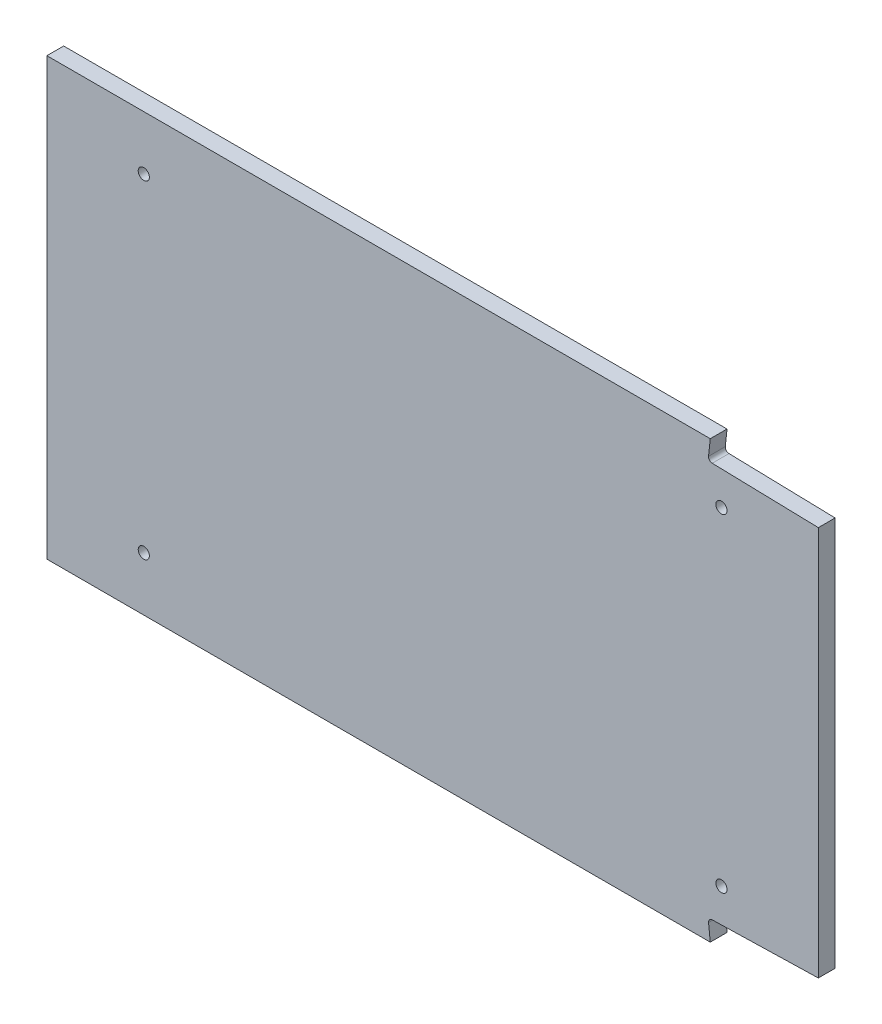
from build123d import *

# Parameters (mm, degrees)
SKETCH1_W               = 207
SKETCH1_H               = 117
BOSS_EXTRUDE1_DEPTH     = 4.5
SKETCH2_R               = 1.5
CUT_EXTRUDE1_DEPTH      = 5.5
MIRROR3_COPY_1_SKETCH_R = 1.5
MIRROR3_COPY_1_DEPTH    = 5.5
CUT_EXTRUDE2_DEPTH      = 4.5


with BuildPart() as part:
    # Sketch1 → Boss-Extrude1 (new body)
    with BuildSketch(Plane.XY):
        Rectangle(SKETCH1_W, SKETCH1_H)
    extrude(amount=BOSS_EXTRUDE1_DEPTH)

    # Sketch2 → Cut-Extrude1 (cut, through all)
    with BuildSketch(Plane.XY.offset(4.5)):
        with Locations((-77.5, 44)):
            Circle(SKETCH2_R)
    cut_extrude1 = extrude(amount=-CUT_EXTRUDE1_DEPTH, mode=Mode.SUBTRACT)

    # Mirror1: Cut-Extrude1 across plane
    add(cut_extrude1.mirror(Plane(origin=(0, 0, 0), x_dir=(0, 0, 1), z_dir=(1, 0, 0))), mode=Mode.SUBTRACT)

    # Mirror3: Cut-Extrude1 across plane
    add(cut_extrude1.mirror(Plane.ZX), mode=Mode.SUBTRACT)

    # Mirror3 copy 1 sketch → Mirror3 copy 1 (cut, through all)
    with BuildSketch(Plane(origin=(0, 0, 4.5), x_dir=(-1, 0, 0), z_dir=(0, 0, 1))):
        with Locations((-77.5, 44)):
            Circle(MIRROR3_COPY_1_SKETCH_R)
    extrude(amount=-MIRROR3_COPY_1_DEPTH, mode=Mode.SUBTRACT)

    # Sketch3 → Cut-Extrude2 (cut)
    with BuildSketch(Plane.XY.offset(4.5)):
        with BuildLine():
            Line((74.50260241, 58.5), (74.041825512, 54.178381356))
            ThreePointArc((74.041825512, 54.178381356), (74.287682649, 53.401965683), (75.025093069, 53.056288231))
            Line((75.025093069, 53.056288231), (103.5, 52.330947596))
            Line((103.5, 52.330947596), (103.5, 58.5))
            Line((103.5, 58.5), (74.50260241, 58.5))
        make_face()
    cut_extrude2 = extrude(amount=-CUT_EXTRUDE2_DEPTH, mode=Mode.SUBTRACT)

    # Mirror4: Cut-Extrude2 across plane
    add(cut_extrude2.mirror(Plane.ZX), mode=Mode.SUBTRACT)


solid = part.part
